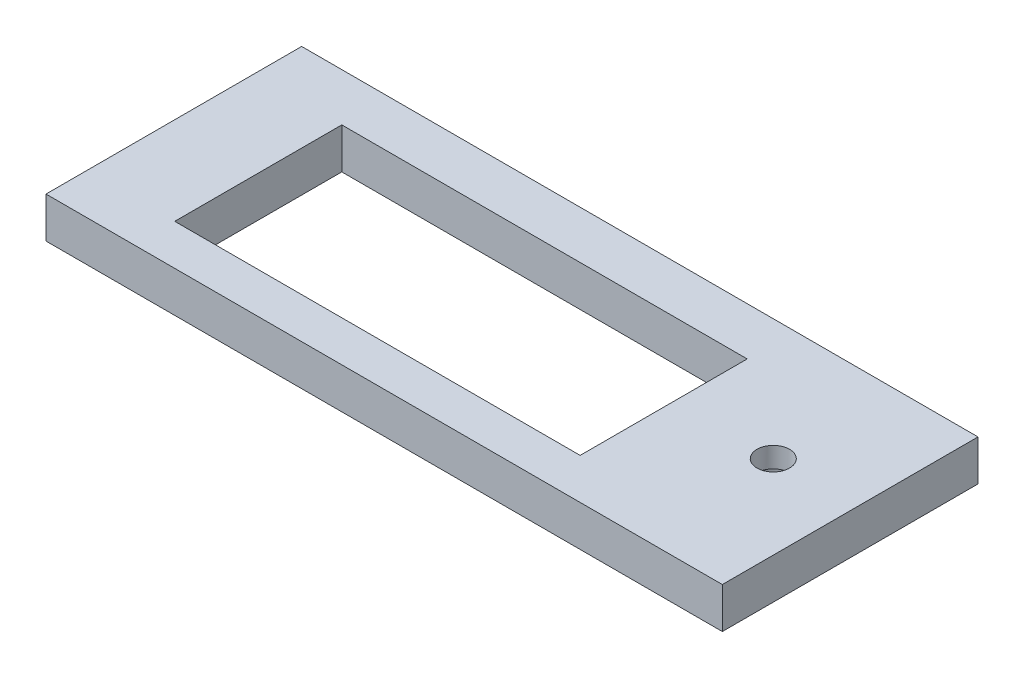
from build123d import *

# Parameters (mm, degrees)
SKETCH2_W                 = 150
SKETCH2_H                 = 62.75
BOSS_EXTRUDE1_DEPTH       = 10
SKETCH3_W                 = 99.5
SKETCH3_H                 = 41
CUT_EXTRUDE1_DEPTH        = 11
SKETCH7_W                 = 70
SKETCH7_H                 = 4
CUT_EXTRUDE4_DEPTH        = 7
SKETCH8_R                 = 4
CUT_EXTRUDE5_DEPTH        = 11
SKETCH9_R                 = 6.5
CUT_EXTRUDE6_DEPTH        = 7
SKETCH10_R                = 3.5
CUT_EXTRUDE7_DEPTH        = 7
SKETCH11_W                = 8
SKETCH11_H                = 62.75
BOSS_EXTRUDE2_DEPTH       = 10
M3X0_5_TAPPED_HOLE2_D     = 2.5
M3X0_5_TAPPED_HOLE2_DEPTH = 25
M3X0_5_TAPPED_HOLE2_TIP   = 0.751075774
M3X0_5_TAPPED_HOLE3_D     = 2.5
M3X0_5_TAPPED_HOLE3_DEPTH = 21
M3X0_5_TAPPED_HOLE3_TIP   = 0.751075774
SKETCH28_R                = 1.5
CUT_EXTRUDE8_DEPTH        = 5.5
SKETCH29_R                = 8.814479729
CUT_EXTRUDE9_DEPTH        = 5


with BuildPart() as part:
    # Sketch2 → Boss-Extrude1 (new body)
    with BuildSketch(Plane(origin=(0, 0, 0), x_dir=(1, 0, 0), z_dir=(0, 1, 0))):
        Rectangle(SKETCH2_W, SKETCH2_H)
    extrude(amount=BOSS_EXTRUDE1_DEPTH)

    # Sketch3 → Cut-Extrude1 (cut, through all)
    with BuildSketch(Plane(origin=(0, 10, 0), x_dir=(1, 0, 0), z_dir=(0, 1, 0))):
        with Locations((-11.65, -0.875)):
            Rectangle(SKETCH3_W, SKETCH3_H)
    extrude(amount=-CUT_EXTRUDE1_DEPTH, mode=Mode.SUBTRACT)

    # Sketch7 → Cut-Extrude4 (cut)
    with BuildSketch(Plane.XZ):
        with Locations((-26.4, -26.575)):
            Rectangle(SKETCH7_W, SKETCH7_H)
    extrude(amount=-CUT_EXTRUDE4_DEPTH, mode=Mode.SUBTRACT)

    # Sketch8 → Cut-Extrude5 (cut, through all)
    with BuildSketch(Plane(origin=(0, 10, 0), x_dir=(1, 0, 0), z_dir=(0, 1, 0))):
        with Locations((62.5, 1.625)):
            Circle(SKETCH8_R)
    extrude(amount=-CUT_EXTRUDE5_DEPTH, mode=Mode.SUBTRACT)

    # Sketch9 → Cut-Extrude6 (cut)
    with BuildSketch(Plane.XZ):
        with Locations((61, -20.625)):
            Circle(SKETCH9_R)
    extrude(amount=-CUT_EXTRUDE6_DEPTH, mode=Mode.SUBTRACT)

    # Sketch10 → Cut-Extrude7 (cut)
    with BuildSketch(Plane(origin=(0, 0, 0), x_dir=(-1, 0, 0), z_dir=(0, -1, 0))):
        with Locations((-62, -14.625)):
            Circle(SKETCH10_R)
    extrude(amount=-CUT_EXTRUDE7_DEPTH, mode=Mode.SUBTRACT)

    # Sketch11 → Boss-Extrude2 (add, through all)
    with BuildSketch(Plane(origin=(0, 10, 0), x_dir=(1, 0, 0), z_dir=(0, 1, 0))):
        with Locations((-79, 0)):
            Rectangle(SKETCH11_W, SKETCH11_H)
        with Locations((79, 0)):
            Rectangle(SKETCH11_W, SKETCH11_H)
    extrude(amount=-BOSS_EXTRUDE2_DEPTH)

    # M3x0.5 Tapped Hole2
    with Locations(Plane(origin=(0, -15.6875, 15.6875), x_dir=(1, 0, 0), z_dir=(0, -0.707106781, 0.707106781))):
        with Locations((79, 6.12547526)):
            Hole(M3X0_5_TAPPED_HOLE2_D / 2, depth=M3X0_5_TAPPED_HOLE2_DEPTH)
            with Locations((0, 0, -(M3X0_5_TAPPED_HOLE2_DEPTH + M3X0_5_TAPPED_HOLE2_TIP / 2))):  # 118° drill point
                Cone(0, M3X0_5_TAPPED_HOLE2_D / 2, M3X0_5_TAPPED_HOLE2_TIP, mode=Mode.SUBTRACT)

    # M3x0.5 Tapped Hole3
    with Locations(Plane(origin=(0, -15.6875, 15.6875), x_dir=(-1, 0, 0), z_dir=(0, -0.707106781, 0.707106781))):
        with Locations((79, -12.12547526)):
            Hole(M3X0_5_TAPPED_HOLE3_D / 2, depth=M3X0_5_TAPPED_HOLE3_DEPTH)
            with Locations((0, 0, -(M3X0_5_TAPPED_HOLE3_DEPTH + M3X0_5_TAPPED_HOLE3_TIP / 2))):  # 118° drill point
                Cone(0, M3X0_5_TAPPED_HOLE3_D / 2, M3X0_5_TAPPED_HOLE3_TIP, mode=Mode.SUBTRACT)

    # Sketch28 → Cut-Extrude8 (cut)
    with BuildSketch(Plane.XZ):
        with Locations((79, -21.375)):
            Circle(SKETCH28_R)
        with Locations((-79, -21.375)):
            Circle(SKETCH28_R)
    extrude(amount=-CUT_EXTRUDE8_DEPTH, mode=Mode.SUBTRACT)

    # Sketch29 → Cut-Extrude9 (cut)
    with BuildSketch(Plane.XZ):
        with Locations((62.5, -1.625)):
            Circle(SKETCH29_R)
    extrude(amount=-CUT_EXTRUDE9_DEPTH, mode=Mode.SUBTRACT)


solid = part.part
